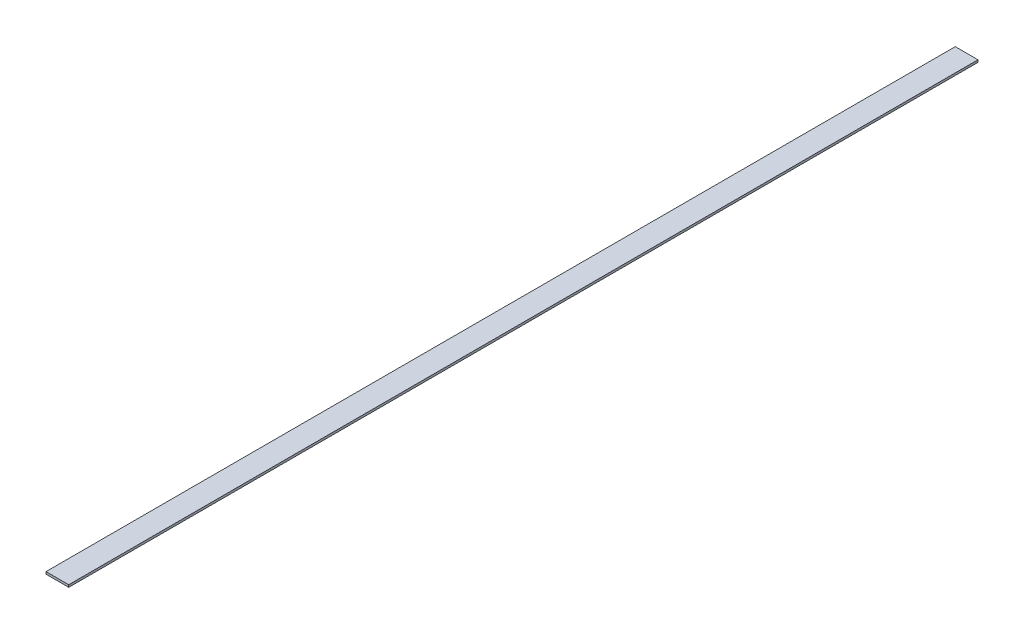
from build123d import *

# Parameters (mm, degrees)
SKETCH1_W           = 30
SKETCH1_H           = 3
BOSS_EXTRUDE1_DEPTH = 1200


with BuildPart() as part:
    # Sketch1 → Boss-Extrude1 (new body)
    with BuildSketch(Plane.XY):
        Rectangle(SKETCH1_W, SKETCH1_H)
    extrude(amount=BOSS_EXTRUDE1_DEPTH)


solid = part.part
